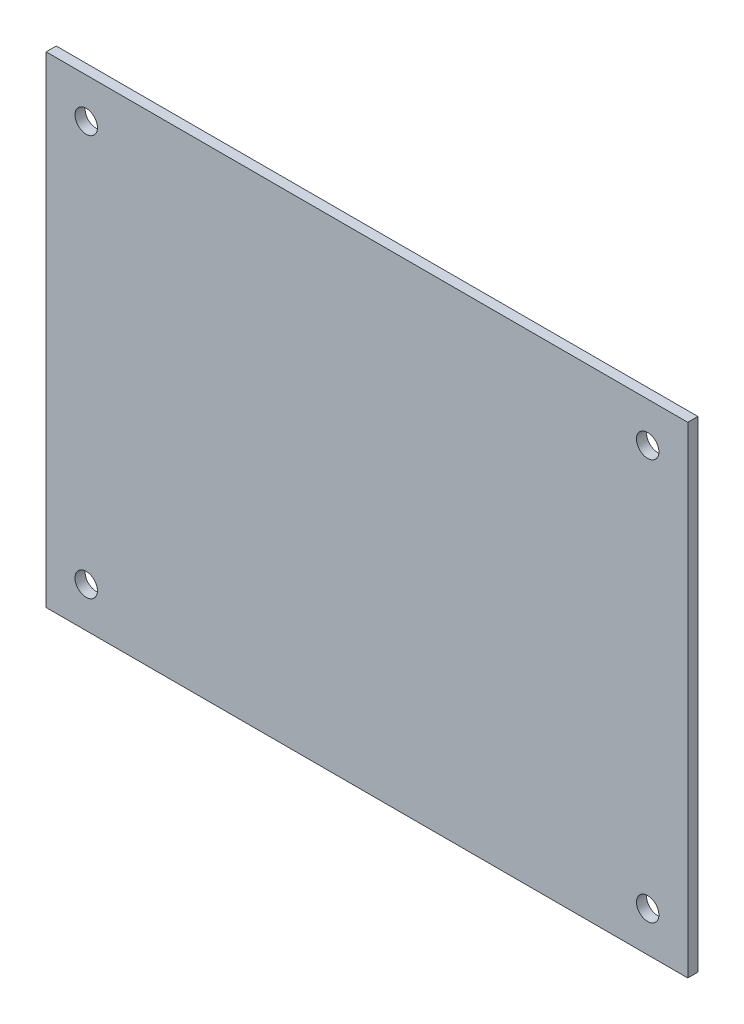
from build123d import *

# Parameters (mm, degrees)
SKETCH1_W            = 101.6
SKETCH1_H            = 76.2
EXTRUDE1_DEPTH       = 1.6002
SKETCH2_R            = 1.778
CUT_EXTRUDE1_DEPTH   = 1.6002
LPATTERN1_COUNT      = 2
LPATTERN1_PITCH      = 63.5
LPATTERN1_COUNT_DIR2 = 2
LPATTERN1_PITCH_DIR2 = 88.9


with BuildPart() as part:
    # Sketch1 → Extrude1 (new body)
    with BuildSketch(Plane.XY):
        with Locations((50.8, -38.1)):
            Rectangle(SKETCH1_W, SKETCH1_H)
    extrude(amount=EXTRUDE1_DEPTH)

    # Sketch2 → Cut-Extrude1 (cut)
    with BuildSketch(Plane.XY.offset(1.6002)):
        with Locations((6.35, -69.85)):
            Circle(SKETCH2_R)
    cut_extrude1 = extrude(amount=-CUT_EXTRUDE1_DEPTH, mode=Mode.SUBTRACT)

    # LPattern1: Cut-Extrude1 2 × 2
    with Locations(*[(j * LPATTERN1_PITCH_DIR2, i * LPATTERN1_PITCH, 0) for i in range(LPATTERN1_COUNT) for j in range(LPATTERN1_COUNT_DIR2) if (i, j) != (0, 0)]):
        add(cut_extrude1, mode=Mode.SUBTRACT)


solid = part.part
